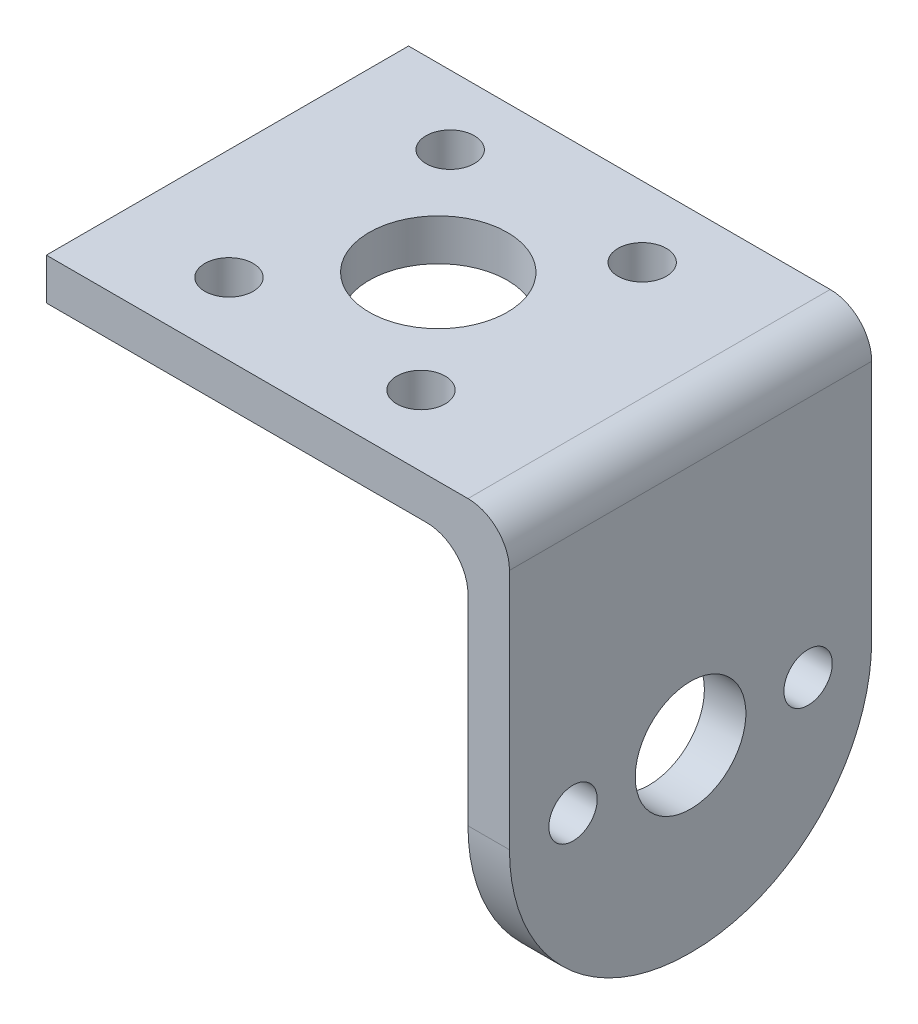
from build123d import *

# Parameters (mm, degrees)
SKETCH1_W               = 33.5
SKETCH1_H               = 26.2
BOSS_EXTRUDE1_DEPTH     = 3
SKETCH3_W               = 3
SKETCH3_H               = 26.2
BOSS_EXTRUDE3_DEPTH     = 30.5
FILLET1_R               = 13
SKETCH7_R               = 1.75
SKETCH7_R_2             = 5
CUT_EXTRUDE1_DEPTH      = 4
FILLET2_R               = 3
SKETCH10_R              = 1.75
SKETCH10_R_2            = 4
CUT_EXTRUDE2_DEPTH      = 1
CUT_EXTRUDE2_DEPTH_BACK = 3.5


with BuildPart() as part:
    # Sketch1 → Boss-Extrude1 (new body)
    with BuildSketch(Plane(origin=(0, 0, 0), x_dir=(1, 0, 0), z_dir=(0, 1, 0))):
        with Locations((16.75, 13.1)):
            Rectangle(SKETCH1_W, SKETCH1_H)
    extrude(amount=BOSS_EXTRUDE1_DEPTH)

    # Sketch3 → Boss-Extrude3 (add)
    with BuildSketch(Plane.XZ):
        with Locations((32, -13.1)):
            Rectangle(SKETCH3_W, SKETCH3_H)
    extrude(amount=BOSS_EXTRUDE3_DEPTH)

    # Fillet1
    fillet1_edges = [part.edges().sort_by_distance(p)[0] for p in [
        (32, -30.5, -26.2),
        (32, -30.5, 0),
    ]]
    fillet(fillet1_edges, radius=FILLET1_R)

    # Sketch7 → Cut-Extrude1 (cut, through all)
    with BuildSketch(Plane.XZ):
        with Locations((8, -5.211347336)):
            Circle(SKETCH7_R)
        with Locations((8, -21.211347336)):
            Circle(SKETCH7_R)
        with Locations((22, -21.1)):
            Circle(SKETCH7_R)
        with Locations((22, -5.1)):
            Circle(SKETCH7_R)
        with Locations((15.25, -13.1)):
            Circle(SKETCH7_R_2)
    extrude(amount=-CUT_EXTRUDE1_DEPTH, mode=Mode.SUBTRACT)

    # Fillet2
    fillet2_edges = [part.edges().sort_by_distance(p)[0] for p in [
        (33.5, 3, -13.1),
        (30.5, 0, -13.1),
    ]]
    fillet(fillet2_edges, radius=FILLET2_R)

    # Sketch10 → Cut-Extrude2 (cut, two sides)
    with BuildSketch(Plane(origin=(33.5, 0, 0), x_dir=(0, 0, -1), z_dir=(1, 0, 0))) as cut_extrude2_sk:
        with Locations((4.6, -17.5)):
            Circle(SKETCH10_R)
        with Locations((21.6, -17.5)):
            Circle(SKETCH10_R)
        with Locations((13.1, -17.5)):
            Circle(SKETCH10_R_2)
    extrude(amount=CUT_EXTRUDE2_DEPTH, mode=Mode.SUBTRACT)
    extrude(cut_extrude2_sk.sketch, amount=-CUT_EXTRUDE2_DEPTH_BACK, mode=Mode.SUBTRACT)


solid = part.part
